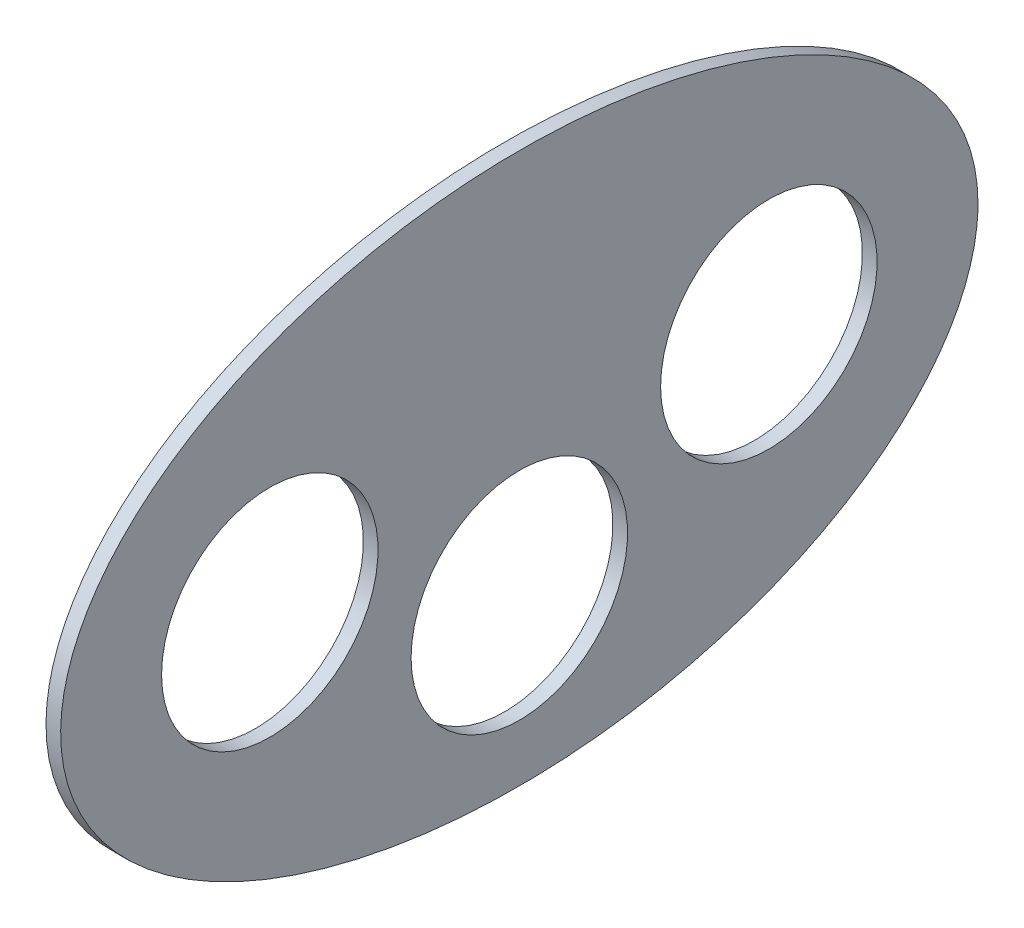
from build123d import *

# Parameters (mm, degrees)
SKETCH1_RX          = 125
SKETCH1_RY          = 75
BOSS_EXTRUDE1_DEPTH = 4
SKETCH2_R           = 29.5
CUT_EXTRUDE1_DEPTH  = 5


with BuildPart() as part:
    # Sketch1 → Boss-Extrude1 (new body)
    with BuildSketch(Plane(origin=(0, 0, 0), x_dir=(0, 0, -1), z_dir=(1, 0, 0))):
        with Locations((0, 0)):
            Ellipse(SKETCH1_RX, SKETCH1_RY)
    extrude(amount=BOSS_EXTRUDE1_DEPTH)

    # Sketch2 → Cut-Extrude1 (cut, through all)
    with BuildSketch(Plane.ZY):
        with Locations((68, 0)):
            Circle(SKETCH2_R)
        with Locations((-68, 0)):
            Circle(SKETCH2_R)
        with Locations((0, -30)):
            Circle(SKETCH2_R)
    extrude(amount=-CUT_EXTRUDE1_DEPTH, mode=Mode.SUBTRACT)


solid = part.part
